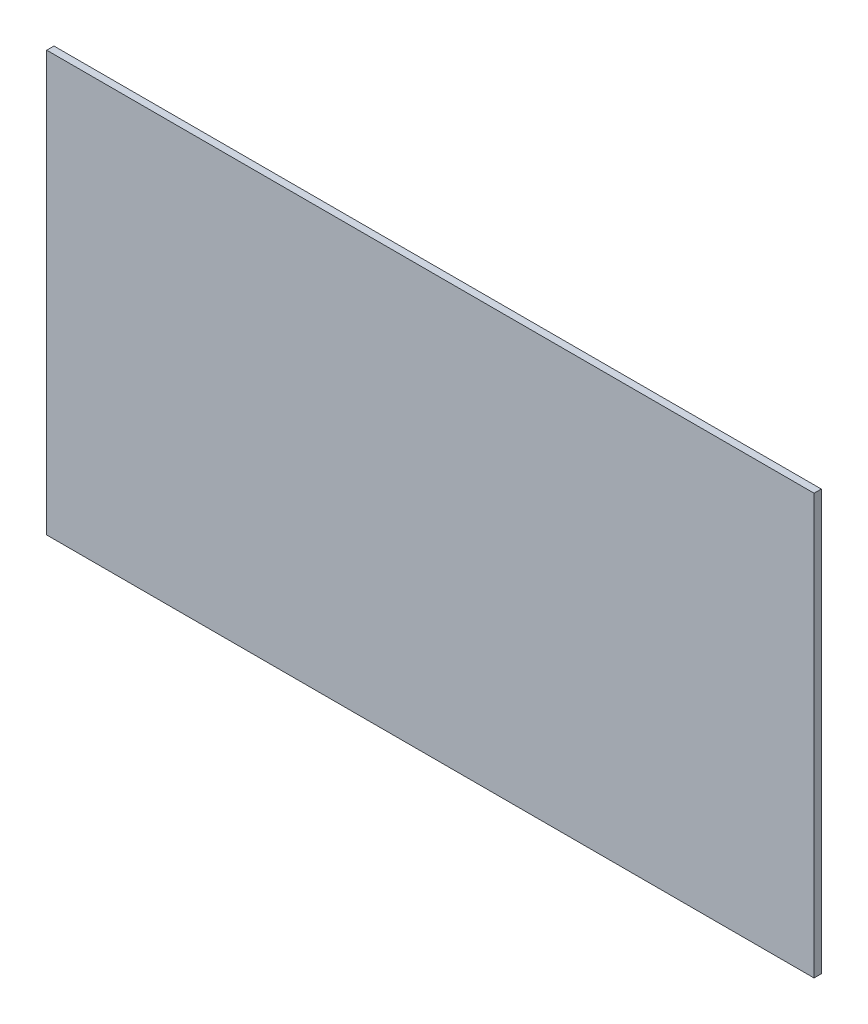
from build123d import *

# Parameters (mm, degrees)
SKETCH1_W           = 13.462
SKETCH1_H           = 7.366
BOSS_EXTRUDE1_DEPTH = 0.127


with BuildPart() as part:
    # Sketch1 → Boss-Extrude1 (new body)
    with BuildSketch(Plane.XY):
        with Locations((-94.473742777, -19.868432242)):
            Rectangle(SKETCH1_W, SKETCH1_H)
    extrude(amount=BOSS_EXTRUDE1_DEPTH)


solid = part.part
